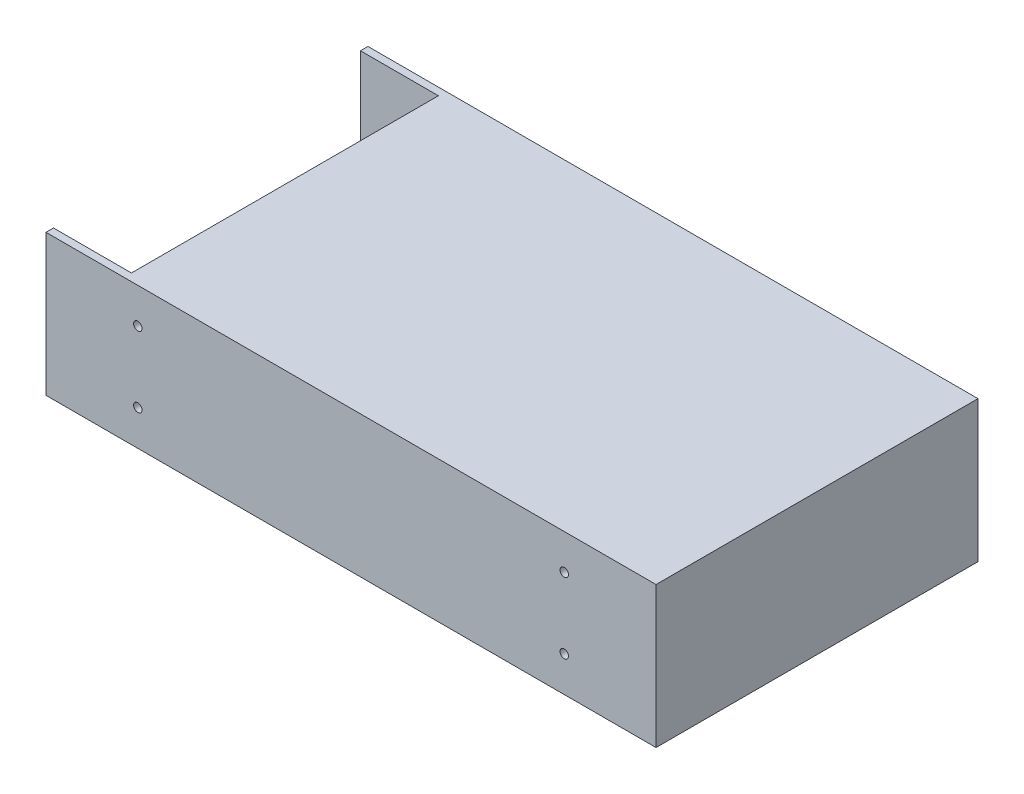
from build123d import *

# Parameters (mm, degrees)
SKETCH_1_W          = 216
SKETCH_1_H          = 114
EXTRUDE_1_DEPTH     = 50
SKETCH_2_W          = 27.595124593
SKETCH_2_H          = 108.683413436
CUT_EXTRUDE_1_DEPTH = 44
SKETCH_3_W          = 15.377269527
SKETCH_3_H          = 95.391197403
EXTRUDE_2_DEPTH     = 10
SKETCH_4_R          = 1.5
CUT_EXTRUDE_2_DEPTH = 115


with BuildPart() as part:
    # 草图1 → 凸台-拉伸1 (new body)
    with BuildSketch(Plane(origin=(0, 0, 0), x_dir=(1, 0, 0), z_dir=(0, 1, 0))):
        Rectangle(SKETCH_1_W, SKETCH_1_H)
    extrude(amount=EXTRUDE_1_DEPTH)

    # 草图2 → 切除-拉伸1 (cut)
    with BuildSketch(Plane(origin=(0, 50, 0), x_dir=(1, 0, 0), z_dir=(0, 1, 0))):
        with Locations((-94.202437704, 0)):
            Rectangle(SKETCH_2_W, SKETCH_2_H)
    extrude(amount=-CUT_EXTRUDE_1_DEPTH, mode=Mode.SUBTRACT)

    # 草图3 → 凸台-拉伸2 (add)
    with BuildSketch(Plane(origin=(0, 6, 0), x_dir=(1, 0, 0), z_dir=(0, 1, 0))):
        with Locations((-94.609302344, 0.130315844)):
            Rectangle(SKETCH_3_W, SKETCH_3_H)
    extrude(amount=EXTRUDE_2_DEPTH)

    # 草图4 → 切除-拉伸2 (cut, through all)
    with BuildSketch(Plane.XY.offset(57)):
        with Locations((75.5, 37.5)):
            Circle(SKETCH_4_R)
        with Locations((75.5, 12.5)):
            Circle(SKETCH_4_R)
        with Locations((-75.5, 12.5)):
            Circle(SKETCH_4_R)
        with Locations((-75.5, 37.5)):
            Circle(SKETCH_4_R)
    extrude(amount=-CUT_EXTRUDE_2_DEPTH, mode=Mode.SUBTRACT)


solid = part.part
